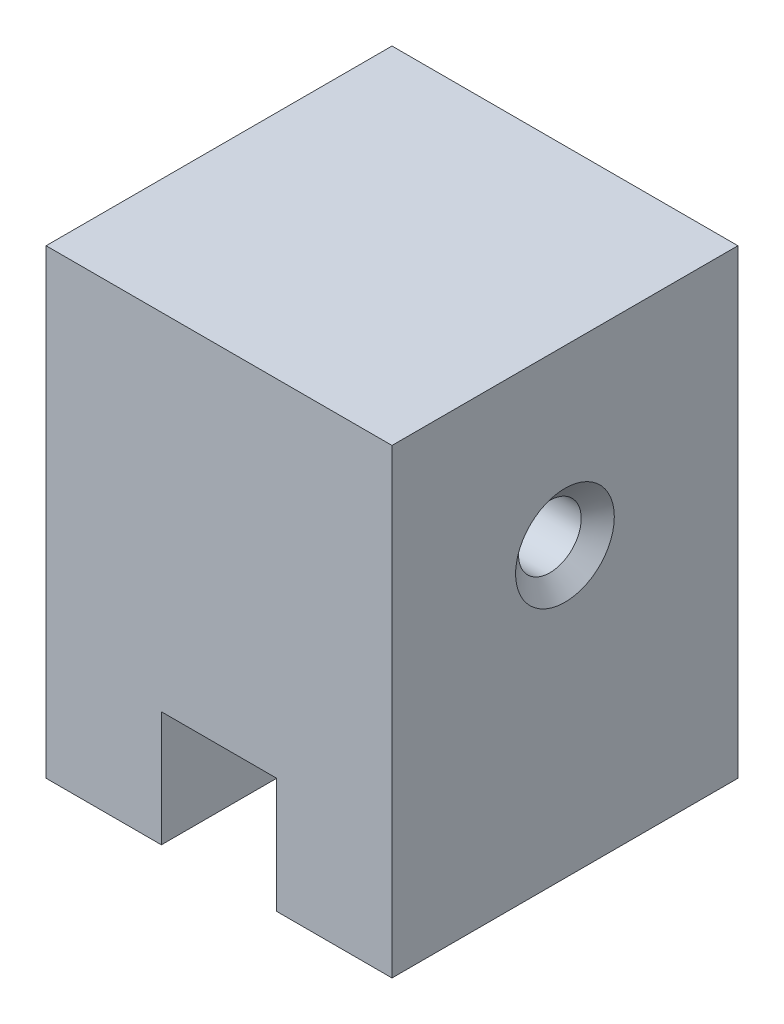
from build123d import *

# Parameters (mm, degrees)
SKETCH1_W                       = 19.05
SKETCH1_H                       = 19.05
BOSS_EXTRUDE1_DEPTH             = 25.4
SKETCH2_W                       = 6.35
SKETCH2_H                       = 6.35
CUT_EXTRUDE1_DEPTH              = 20.05
F_8_32_TAPPED_HOLE1_D           = 3.4544
F_8_32_TAPPED_HOLE1_CSINK_D     = 5.4356
F_8_32_TAPPED_HOLE1_CSINK_ANGLE = 100


with BuildPart() as part:
    # Sketch1 → Boss-Extrude1 (new body)
    with BuildSketch(Plane(origin=(0, 0, 0), x_dir=(1, 0, 0), z_dir=(0, 1, 0))):
        Rectangle(SKETCH1_W, SKETCH1_H)
    extrude(amount=BOSS_EXTRUDE1_DEPTH)

    # Sketch2 → Cut-Extrude1 (cut, through all)
    with BuildSketch(Plane.XY.offset(9.525)):
        with Locations((0, 3.175)):
            Rectangle(SKETCH2_W, SKETCH2_H)
    extrude(amount=-CUT_EXTRUDE1_DEPTH, mode=Mode.SUBTRACT)

    # #8-32 Tapped Hole1 (through all)
    with Locations(Plane(origin=(9.525, 0, 0), x_dir=(0, 0, 1), z_dir=(1, 0, 0))):
        with Locations((0, -15.875)):
            CounterSinkHole(F_8_32_TAPPED_HOLE1_D / 2, F_8_32_TAPPED_HOLE1_CSINK_D / 2, counter_sink_angle=F_8_32_TAPPED_HOLE1_CSINK_ANGLE)


solid = part.part
